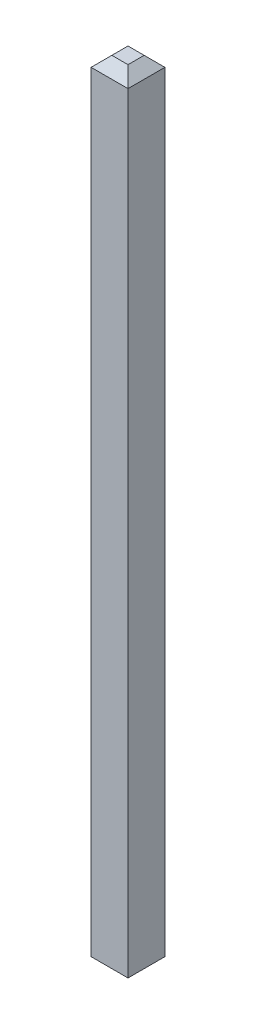
from build123d import *

# Parameters (mm, degrees)
ESQUISSE1_W        = 0.3556
ESQUISSE1_H        = 7.62
BOSS_EXTRU_1_DEPTH = 0.3556
CHANFREIN1_SIZE    = 0.1


with BuildPart() as part:
    # Esquisse1 → Boss.-Extru.1 (new body)
    with BuildSketch(Plane.XY):
        with Locations((0, 3.81)):
            Rectangle(ESQUISSE1_W, ESQUISSE1_H)
    extrude(amount=BOSS_EXTRU_1_DEPTH)

    # Chanfrein1
    chanfrein1_edges = [part.edges().sort_by_distance(p)[0] for p in [
        (0, 7.62, 0.3556),
        (0, 7.62, 0),
        (0, 0, 0),
        (0, 0, 0.3556),
        (-0.1778, 7.62, 0.1778),
        (0.1778, 7.62, 0.1778),
        (0.1778, 0, 0.1778),
        (-0.1778, 0, 0.1778),
    ]]
    chamfer(chanfrein1_edges, length=CHANFREIN1_SIZE)


solid = part.part
